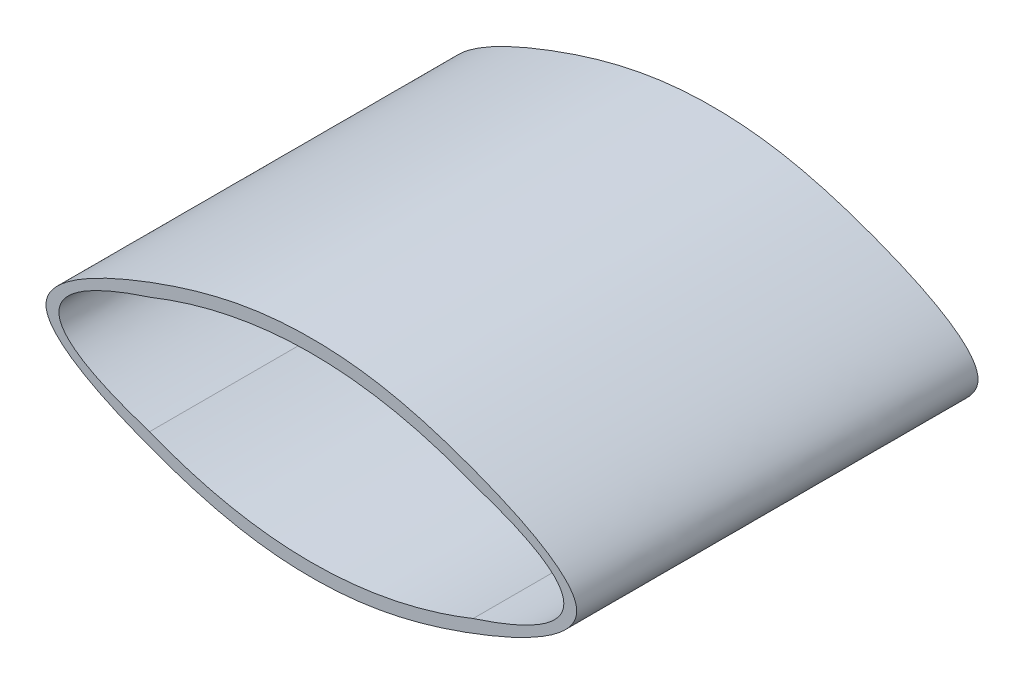
from build123d import *

# Parameters (mm, degrees)
BOSS_EXTRUDE1_DEPTH = 31
SKETCH2_W           = 2
SKETCH2_H           = 2.440972957
SKETCH2_H_2         = 2.255456279
BOSS_EXTRUDE2_DEPTH = 1


with BuildPart() as part:
    # Sketch1 → Boss-Extrude1 (new body)
    with BuildSketch(Plane.XY):
        with BuildLine():
            add(Edge.make_bspline(
                [(-8, 7), (-8, 9.055361365), (1.947467769, 13.80954442), (12.5, 15.675789574), (23.052532231, 13.80954442), (37.300558202, 7), (23.052532231, 0.19045558), (12.5, -1.675789574), (1.947467769, 0.19045558), (-8, 4.944638635), (-8, 7)],
                knots=[0, 0, 0, 0, 0.108081732, 0.25, 0.391918268, 0.5, 0.608081732, 0.75, 0.891918268, 1, 1, 1, 1], degree=3))
        make_face()
        with BuildLine():
            add(Edge.make_bspline(
                [(0, 2.5), (12.5, -2.5), (25, 2.5)],
                knots=[0, 0, 0, 1, 1, 1], degree=2))
            add(Edge.make_bspline(
                [(25, 11.5), (39, 7), (25, 2.5)],
                knots=[0, 0, 0, 1, 1, 1], degree=2))
            add(Edge.make_bspline(
                [(0, 11.5), (12.5, 16.5), (25, 11.5)],
                knots=[0, 0, 0, 1, 1, 1], degree=2))
            add(Edge.make_bspline(
                [(0, 2.5), (-14, 7), (0, 11.5)],
                knots=[0, 0, 0, 1, 1, 1], degree=2))
        make_face(mode=Mode.SUBTRACT)
    extrude(amount=BOSS_EXTRUDE1_DEPTH)

    # Sketch2 → Boss-Extrude2 (add)
    with BuildSketch(Plane(origin=(0, 0, 0), x_dir=(-1, 0, 0), z_dir=(0, 0, -1))):
        with BuildLine():
            Line((-17.998917889, 14.502458301), (-17.998917889, 13.516190433))
            add(Edge.make_bspline(
                [(-17.998917889, 13.516190433), (-16.998917889, 13.692155805), (-15.998917889, 13.804121178)],
                knots=[0.280043284, 0.280043284, 0.280043284, 0.360043284, 0.360043284, 0.360043284], degree=2))
            Line((-15.998917889, 13.804121178), (-15.998917889, 14.502458301))
            Line((-15.998917889, 14.502458301), (-15.998917889, 14.801112463))
            Line((-15.998917889, 14.801112463), (-17.998917889, 14.502458301))
        make_face()
        with BuildLine():
            Line((-17.998917889, 13.516190433), (-17.998917889, 6.943431258))
            Line((-17.998917889, 6.943431258), (-15.998917889, 6.943431258))
            Line((-15.998917889, 6.943431258), (-15.998917889, 13.804121178))
            add(Edge.make_bspline(
                [(-17.998917889, 13.516190433), (-16.998917889, 13.692155805), (-15.998917889, 13.804121178)],
                knots=[0.280043284, 0.280043284, 0.280043284, 0.360043284, 0.360043284, 0.360043284], degree=2))
        make_face()
        with Locations((-16.998917889, 5.72294478)):
            Rectangle(SKETCH2_W, SKETCH2_H)
        with BuildLine():
            Line((-7.001082111, 6.943431258), (-9.001082111, 6.943431258))
            Line((-9.001082111, 6.943431258), (-9.001082111, 0.195878822))
            add(Edge.make_bspline(
                [(-7.001082111, 0.483809567), (-8.001082111, 0.307844195), (-9.001082111, 0.195878822)],
                knots=[0.280043284, 0.280043284, 0.280043284, 0.360043284, 0.360043284, 0.360043284], degree=2))
            Line((-7.001082111, 0.483809567), (-7.001082111, 6.943431258))
        make_face()
        with Locations((-8.001082111, 8.071159398)):
            Rectangle(SKETCH2_W, SKETCH2_H_2)
        with BuildLine():
            add(Edge.make_bspline(
                [(-7.001082111, 0.483809567), (-8.001082111, 0.307844195), (-9.001082111, 0.195878822)],
                knots=[0.280043284, 0.280043284, 0.280043284, 0.360043284, 0.360043284, 0.360043284], degree=2))
            Line((-9.001082111, 0.195878822), (-9.001082111, -0.801112463))
            Line((-9.001082111, -0.801112463), (-7.001082111, -0.502458301))
            Line((-7.001082111, -0.502458301), (-7.001082111, 0.483809567))
        make_face()
    extrude(amount=-BOSS_EXTRUDE2_DEPTH)


solid = part.part
